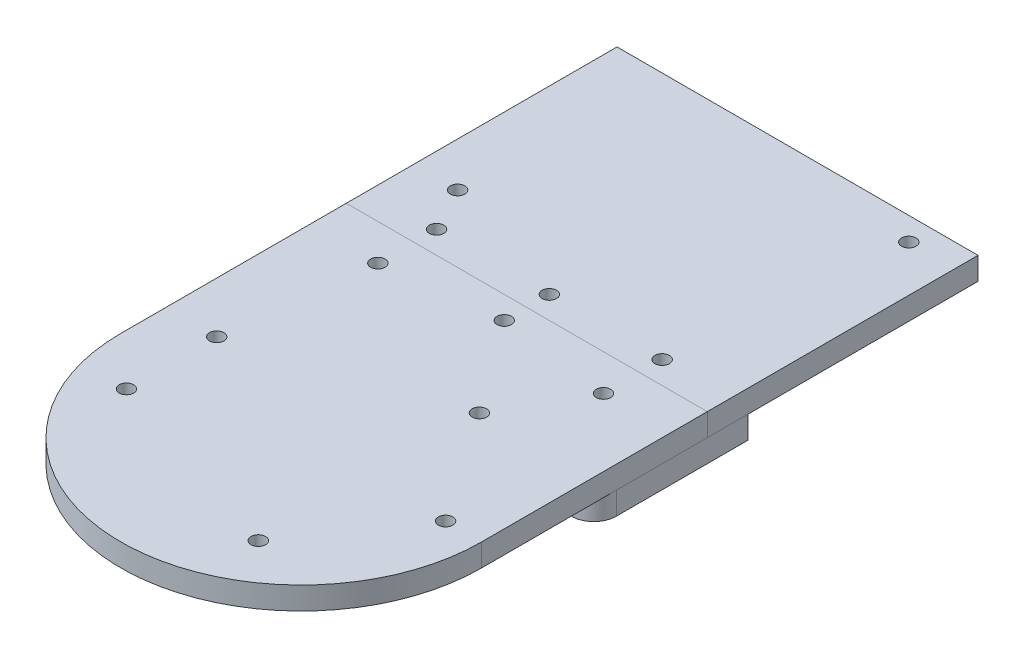
from build123d import *

# Parameters (mm, degrees)
EXTRUDE_1_DEPTH          = 5
SKETCH_2_R               = 1.6
CUT_EXTRUDE_1_DEPTH      = 10
SKETCH_3_R               = 1.6
CUT_EXTRUDE_2_DEPTH      = 10
SKETCH_4_R               = 1.6
CUT_EXTRUDE_3_DEPTH      = 10
SKETCH_5_R               = 1.6
CUT_EXTRUDE_4_DEPTH      = 1
CUT_EXTRUDE_4_DEPTH_BACK = 6
EXTRUDE_2_DEPTH          = 5
FILLET_1_R               = 5
SKETCH_7_R               = 1.6
CUT_EXTRUDE_5_DEPTH      = 39


with BuildPart() as part:
    # 草图1 → 凸台-拉伸1 (new body)
    with BuildSketch(Plane(origin=(0, 0, 0), x_dir=(1, 0, 0), z_dir=(0, 1, 0))):
        with BuildLine():
            Line((-40, 0), (-40, 110))
            Line((-40, 110), (40, 110))
            Line((40, 110), (40, 0))
            ThreePointArc((40, 0), (0, -40), (-40, 0))
        make_face()
    extrude(amount=EXTRUDE_1_DEPTH)

    # 草图2 → 切除-拉伸1 (cut)
    with BuildSketch(Plane(origin=(0, 5, 0), x_dir=(1, 0, 0), z_dir=(0, 1, 0))):
        with Locations((15, 24.5)):
            Circle(SKETCH_2_R)
        with Locations((15, -24.5)):
            Circle(SKETCH_2_R)
    extrude(amount=-CUT_EXTRUDE_1_DEPTH, mode=Mode.SUBTRACT)

    # 草图3 → 切除-拉伸2 (cut)
    with BuildSketch(Plane.XZ):
        with Locations((32, 0)):
            Circle(SKETCH_3_R)
        with Locations((-28.725, 10)):
            Circle(SKETCH_3_R)
        with Locations((-28.725, -10)):
            Circle(SKETCH_3_R)
    extrude(amount=-CUT_EXTRUDE_2_DEPTH, mode=Mode.SUBTRACT)

    # 草图4 → 切除-拉伸3 (cut)
    with BuildSketch(Plane(origin=(0, 5, 0), x_dir=(1, 0, 0), z_dir=(0, 1, 0))):
        with Locations((29.78201983, 104.879)):
            Circle(SKETCH_4_R)
        with Locations((-30.21798017, 64.879)):
            Circle(SKETCH_4_R)
    extrude(amount=-CUT_EXTRUDE_3_DEPTH, mode=Mode.SUBTRACT)


with BuildPart() as body_2:
    # Split Bodies 1: the piece on the far side of the plane
    add(part.part)
    split(bisect_by=Plane(origin=(0, 0, -50), x_dir=(-1, 0, 0), z_dir=(0, 0, -1)), keep=Keep.BOTTOM)


with BuildPart() as part_1:
    add(part.part)

    # Split Bodies 1
    split(bisect_by=Plane(origin=(0, 0, -50), x_dir=(-1, 0, 0), z_dir=(0, 0, -1)), keep=Keep.TOP)


with BuildPart() as cut_extrude_4_tool:
    # 草图5 → 切除-拉伸4 (new body, two sides)
    with BuildSketch(Plane.XZ) as cut_extrude_4_sk:
        with Locations((25, -55)):
            Circle(SKETCH_5_R)
        with Locations((0, -55)):
            Circle(SKETCH_5_R)
        with Locations((-25, -55)):
            Circle(SKETCH_5_R)
        with Locations((0, -45)):
            Circle(SKETCH_5_R)
        with Locations((-25, -42)):
            Circle(SKETCH_5_R)
        with Locations((25, -42)):
            Circle(SKETCH_5_R)
    extrude(amount=CUT_EXTRUDE_4_DEPTH)
    extrude(cut_extrude_4_sk.sketch, amount=-CUT_EXTRUDE_4_DEPTH_BACK)


with BuildPart() as part_2:
    add(part_1.part)

    # 切除-拉伸4: cut by cut_extrude_4_tool
    add(cut_extrude_4_tool.part, mode=Mode.SUBTRACT)


with BuildPart() as body_2_1:
    add(body_2.part)

    # 切除-拉伸4: cut by cut_extrude_4_tool
    add(cut_extrude_4_tool.part, mode=Mode.SUBTRACT)


with BuildPart() as body_3:
    # 草图6 → 凸台-拉伸2 (new body)
    with BuildSketch(Plane.XZ):
        with BuildLine():
            Line((-40, -9), (-40, -59))
            Line((-40, -59), (40, -59))
            Line((40, -59), (40, -9))
            ThreePointArc((40, -9), (0, -41), (-40, -9))
        make_face()
    extrude(amount=EXTRUDE_2_DEPTH)

    # 圆角1
    fillet_1_edges = [body_3.edges().sort_by_distance(p)[0] for p in [
        (40, -2.5, -9),
        (-40, -2.5, -9),
    ]]
    fillet(fillet_1_edges, radius=FILLET_1_R)

    # 草图7 → 切除-拉伸5 (cut)
    with BuildSketch(Plane(origin=(0, 5, 0), x_dir=(1, 0, 0), z_dir=(0, 1, 0))):
        with Locations((25, 42)):
            Circle(SKETCH_7_R)
        with Locations((25, 55)):
            Circle(SKETCH_7_R)
        with Locations((0, 45)):
            Circle(SKETCH_7_R)
        with Locations((0, 55)):
            Circle(SKETCH_7_R)
        with Locations((-25, 42)):
            Circle(SKETCH_7_R)
        with Locations((-25, 55)):
            Circle(SKETCH_7_R)
    extrude(amount=-CUT_EXTRUDE_5_DEPTH, mode=Mode.SUBTRACT)


solid = Compound([part_2.part, body_2_1.part, body_3.part])
